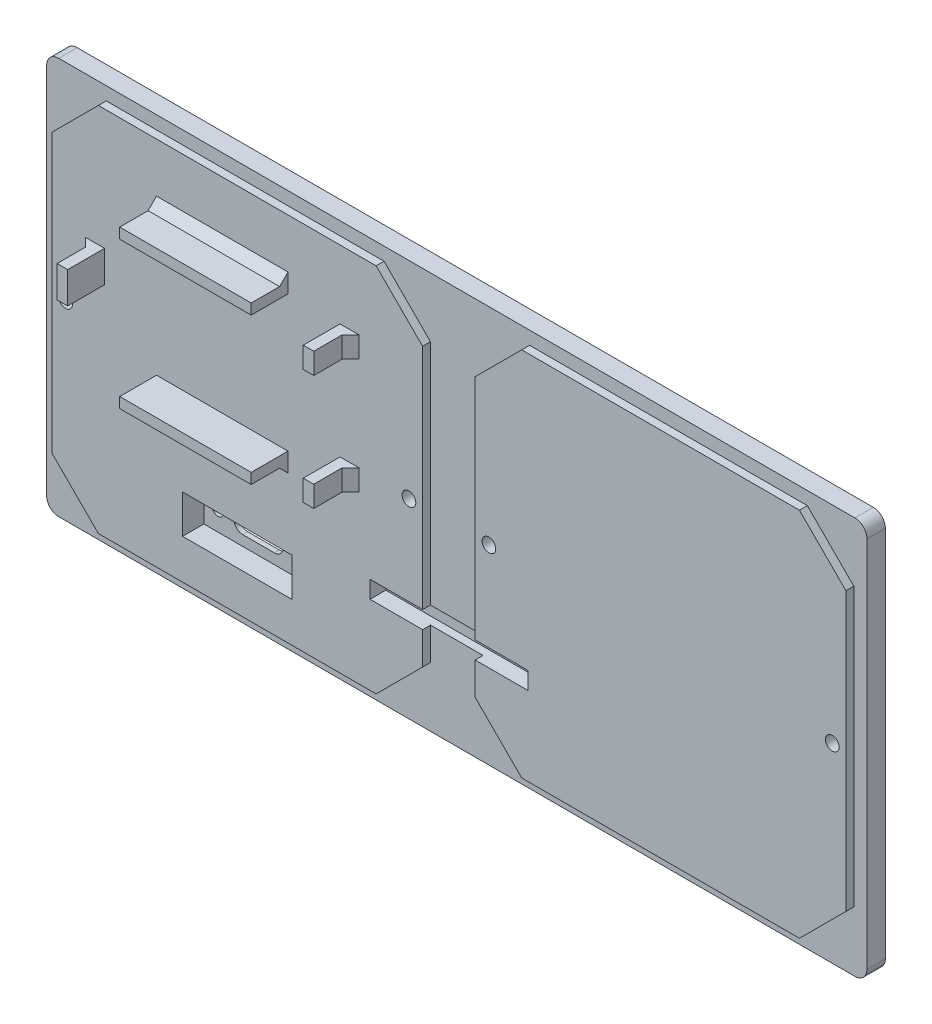
from build123d import *

# Parameters (mm, degrees)
SKETCH_1_W          = 156
SKETCH_1_H          = 75.5
SKETCH_1_R          = 1.3
EXTRUDE_1_DEPTH     = 5
FILLET_1_R          = 2.3
CUT_EXTRUDE_1_DEPTH = 1.5
SKETCH_5_R          = 2.55
SKETCH_5_R_2        = 1.3
CUT_EXTRUDE_4_DEPTH = 2.8
SKETCH_3_R          = 1.05
CUT_EXTRUDE_2_DEPTH = 6
SKETCH_4_W          = 20.8
SKETCH_4_H          = 7.3
CUT_EXTRUDE_3_DEPTH = 4.05
SKETCH_6_W          = 30
SKETCH_6_H          = 3.3
CUT_EXTRUDE_5_DEPTH = 3
SKETCH_7_W          = 25
SKETCH_7_H          = 2
SKETCH_7_W_2        = 2
SKETCH_7_H_2        = 6
SKETCH_7_H_3        = 4
EXTRUDE_2_DEPTH     = 7
CHAMFER_1_SIZE      = 1.6
SKETCH_8_W          = 2.463786805
SKETCH_8_H          = 8
CUT_EXTRUDE_6_DEPTH = 0.5


with BuildPart() as part:
    # 草图1 → 凸台-拉伸1 (new body)
    with BuildSketch(Plane.XY):
        Rectangle(SKETCH_1_W, SKETCH_1_H)
        with Locations((-72.9, 0)):
            Circle(SKETCH_1_R, mode=Mode.SUBTRACT)
        with Locations((-7.6, 0)):
            Circle(SKETCH_1_R, mode=Mode.SUBTRACT)
        with Locations((7.6, 0)):
            Circle(SKETCH_1_R, mode=Mode.SUBTRACT)
        with Locations((72.9, 0)):
            Circle(SKETCH_1_R, mode=Mode.SUBTRACT)
    extrude(amount=EXTRUDE_1_DEPTH)

    # 圆角1
    fillet_1_edges = [part.edges().sort_by_distance(p)[0] for p in [
        (78, -37.75, 2.5),
        (-78, -37.75, 2.5),
        (-78, 37.75, 2.5),
        (78, 37.75, 2.5),
    ]]
    fillet(fillet_1_edges, radius=FILLET_1_R)

    # 草图2 → 切除-拉伸1 (cut)
    with BuildSketch(Plane.XY.offset(5)):
        with BuildLine():
            Line((-75.7, -37.75), (75.7, -37.75))
            ThreePointArc((75.7, -37.75), (77.326345597, -37.076345597), (78, -35.45))
            Line((78, -35.45), (78, 35.45))
            ThreePointArc((78, 35.45), (77.326345597, 37.076345597), (75.7, 37.75))
            Line((75.7, 37.75), (-75.7, 37.75))
            ThreePointArc((-75.7, 37.75), (-77.326345597, 37.076345597), (-78, 35.45))
            Line((-78, 35.45), (-78, -35.45))
            ThreePointArc((-78, -35.45), (-77.326345597, -37.076345597), (-75.7, -37.75))
        make_face()
        Polygon((-75.5, 26.411165235), (-75.5, -26.411165235), (-66.661165235, -35.25), (-13.838834765, -35.25), (-5, -26.411165235), (-5, 26.411165235), (-13.838834765, 35.25), (-66.661165235, 35.25), align=None, mode=Mode.SUBTRACT)
        Polygon((66.661165235, 35.25), (75.5, 26.411165235), (75.5, -26.411165235), (66.661165235, -35.25), (13.838834765, -35.25), (5, -26.411165235), (5, 26.411165235), (13.838834765, 35.25), align=None, mode=Mode.SUBTRACT)
    extrude(amount=-CUT_EXTRUDE_1_DEPTH, mode=Mode.SUBTRACT)

    # 草图5 → 切除-拉伸4 (cut)
    with BuildSketch(Plane(origin=(0, 0, 0), x_dir=(-1, 0, 0), z_dir=(0, 0, -1))):
        with Locations((72.9, 0)):
            Circle(SKETCH_5_R)
        with Locations((72.9, 0)):
            Circle(SKETCH_5_R_2, mode=Mode.SUBTRACT)
        with Locations((7.6, 0)):
            Circle(SKETCH_5_R)
        with Locations((7.6, 0)):
            Circle(SKETCH_5_R_2, mode=Mode.SUBTRACT)
        with Locations((-7.6, 0)):
            Circle(SKETCH_5_R)
        with Locations((-7.6, 0)):
            Circle(SKETCH_5_R_2, mode=Mode.SUBTRACT)
        with Locations((-72.9, 0)):
            Circle(SKETCH_5_R)
        with Locations((-72.9, 0)):
            Circle(SKETCH_5_R_2, mode=Mode.SUBTRACT)
    extrude(amount=-CUT_EXTRUDE_4_DEPTH, mode=Mode.SUBTRACT)

    # 草图3 → 切除-拉伸2 (cut, through all)
    with BuildSketch(Plane(origin=(0, 0, 0), x_dir=(-1, 0, 0), z_dir=(0, 0, -1))):
        with Locations((47.95, -24.05)):
            Circle(SKETCH_3_R)
        with Locations((32.55, -24.05)):
            Circle(SKETCH_3_R)
        with BuildLine():
            Line((37.25, -22.35), (43.25, -22.35))
            ThreePointArc((43.25, -22.35), (44.95, -24.05), (43.25, -25.75))
            Line((43.25, -25.75), (37.25, -25.75))
            ThreePointArc((37.25, -25.75), (35.55, -24.05), (37.25, -22.35))
        make_face()
    extrude(amount=-CUT_EXTRUDE_2_DEPTH, mode=Mode.SUBTRACT)

    # 草图4 → 切除-拉伸3 (cut)
    with BuildSketch(Plane.XY.offset(5)):
        with Locations((-40.25, -24.05)):
            Rectangle(SKETCH_4_W, SKETCH_4_H)
    extrude(amount=-CUT_EXTRUDE_3_DEPTH, mode=Mode.SUBTRACT)

    # 草图6 → 切除-拉伸5 (cut)
    with BuildSketch(Plane.XY.offset(5)):
        with Locations((0, -18.6)):
            Rectangle(SKETCH_6_W, SKETCH_6_H)
    extrude(amount=-CUT_EXTRUDE_5_DEPTH, mode=Mode.SUBTRACT)

    # 草图7 → 凸台-拉伸2 (add)
    with BuildSketch(Plane.XY.offset(5)):
        with Locations((-43.1, 23.25)):
            Rectangle(SKETCH_7_W, SKETCH_7_H)
        with Locations((-66.5, 9.3)):
            Rectangle(SKETCH_7_W_2, SKETCH_7_H_2)
        with Locations((-19.7, 20.25)):
            Rectangle(SKETCH_7_W_2, SKETCH_7_H_3)
        with Locations((-19.7, -1.65)):
            Rectangle(SKETCH_7_W_2, SKETCH_7_H_3)
        with Locations((-43.1, -4.65)):
            Rectangle(SKETCH_7_W, SKETCH_7_H)
    extrude(amount=EXTRUDE_2_DEPTH)

    # 倒角1
    chamfer_1_edges = [part.edges().sort_by_distance(p)[0] for p in [
        (-18.7, -1.65, 5),
        (-18.7, 20.25, 5),
        (-43.1, 24.25, 5),
        (-67.5, 9.3, 5),
        (-43.1, -5.65, 5),
    ]]
    chamfer(chamfer_1_edges, length=CHAMFER_1_SIZE)

    # 草图8 → 切除-拉伸6 (cut)
    with BuildSketch(Plane(origin=(0, 0, 0), x_dir=(-1, 0, 0), z_dir=(0, 0, -1))):
        with BuildLine():
            Line((-26.414210856, 18.390338405), (-26.414210856, 20.652964668))
            add(Edge.make_bspline(
                [(-26.414210856, 20.652964668), (-26.359678019, 20.65405805), (-26.257047942, 20.656115782), (-26.114127978, 20.676912332), (-25.991758174, 20.707870079), (-25.890997156, 20.754581783), (-25.810585553, 20.815106678), (-25.753828372, 20.89152807), (-25.719066321, 20.981436143), (-25.716030587, 21.045791122), (-25.714447263, 21.079356243)],
                knots=[0, 0, 0, 0, 0.00016348, 0.000307668, 0.000432375, 0.000540815, 0.000638831, 0.000730987, 0.000822951, 0.000923204, 0.000923204, 0.000923204, 0.000923204], degree=3))
            add(Edge.make_bspline(
                [(-25.714447263, 21.079356243), (-25.715817062, 21.109230751), (-25.718403571, 21.165640995), (-25.736289996, 21.245528584), (-25.771865042, 21.312076708), (-25.819401012, 21.36771954), (-25.881481297, 21.409296442), (-25.956551854, 21.438472858), (-26.044171961, 21.457716866), (-26.107486225, 21.458770908), (-26.140838838, 21.459326155)],
                knots=[0, 0, 0, 0, 8.9669e-05, 0.000169316, 0.000243147, 0.000313828, 0.000386792, 0.000464695, 0.000554397, 0.000654251, 0.000654251, 0.000654251, 0.000654251], degree=3))
            add(Edge.make_bspline(
                [(-26.140838838, 21.459326155), (-26.165765415, 21.457896018), (-26.213681094, 21.455146904), (-26.280311418, 21.427379433), (-26.337699668, 21.382994583), (-26.381705722, 21.318772687), (-26.416834978, 21.238992898), (-26.438801072, 21.142171263), (-26.455071284, 21.028892846), (-26.456452425, 20.947617442), (-26.457193878, 20.903985515)],
                knots=[0, 0, 0, 0, 7.4429e-05, 0.000143073, 0.000212891, 0.000289241, 0.000373908, 0.000473153, 0.000585975, 0.000716745, 0.000716745, 0.000716745, 0.000716745], degree=3))
            Line((-26.457193878, 20.903985515), (-26.457193878, 15.708197851))
            Line((-26.457193878, 15.708197851), (-29.108386656, 15.708197851))
            Line((-29.108386656, 15.708197851), (-29.108386656, 20.65812263))
            add(Edge.make_bspline(
                [(-29.108386656, 20.65812263), (-29.107362968, 20.74295817), (-29.105355323, 20.909336543), (-29.090656501, 21.152789654), (-29.06183282, 21.384295781), (-29.0274188, 21.604594435), (-28.978715342, 21.812850091), (-28.920582328, 22.0093702), (-28.851901836, 22.193921309), (-28.772086547, 22.367491754), (-28.681180517, 22.532064123), (-28.574461301, 22.686980754), (-28.45856355, 22.837329949), (-28.327133397, 22.977984795), (-28.183469635, 23.111260696), (-28.026481473, 23.236919197), (-27.856034306, 23.355111906), (-27.674822824, 23.466189922), (-27.485592644, 23.567948484), (-27.288710518, 23.653039972), (-27.089015198, 23.727156116), (-26.886259235, 23.790020997), (-26.679133684, 23.836099132), (-26.468281992, 23.868316225), (-26.253620483, 23.890079648), (-26.108798056, 23.892611248), (-26.035960265, 23.893884504)],
                knots=[0, 0, 0, 0, 0.000254512, 0.000499145, 0.000731171, 0.000954186, 0.001167721, 0.001372255, 0.001568657, 0.001757907, 0.001944942, 0.002131875, 0.002321725, 0.002513951, 0.002708607, 0.002909186, 0.003116662, 0.003330446, 0.003546575, 0.003760601, 0.003973304, 0.004185416, 0.004396892, 0.004609178, 0.004825081, 0.005043543, 0.005043543, 0.005043543, 0.005043543], degree=3))
            add(Edge.make_bspline(
                [(-26.035960265, 23.893884504), (-25.929801347, 23.891264376), (-25.72188437, 23.886132737), (-25.416942069, 23.845141815), (-25.125242381, 23.780819757), (-24.846823776, 23.687550294), (-24.582694486, 23.566396664), (-24.33219747, 23.419449272), (-24.094957579, 23.246648337), (-23.875891921, 23.048120508), (-23.675200679, 22.832777937), (-23.498925703, 22.604010013), (-23.351046061, 22.363716069), (-23.2264363, 22.114277373), (-23.132694053, 21.852573022), (-23.065146674, 21.580757004), (-23.024853091, 21.298344525), (-23.01953575, 21.106422536), (-23.01683282, 21.008864088)],
                knots=[0, 0, 0, 0, 0.000318372, 0.000623545, 0.000921365, 0.001213331, 0.001502611, 0.00179159, 0.002083212, 0.002381488, 0.002677116, 0.002965291, 0.003246319, 0.00352236, 0.003800279, 0.004078416, 0.004361442, 0.00465405, 0.00465405, 0.00465405, 0.00465405], degree=3))
            add(Edge.make_bspline(
                [(-23.01683282, 21.008864088), (-23.018985353, 20.911883277), (-23.023191503, 20.722378189), (-23.060637932, 20.446243019), (-23.118370819, 20.184577808), (-23.20084919, 19.937654889), (-23.308409534, 19.705481562), (-23.439271653, 19.487663135), (-23.595327691, 19.286055659), (-23.772399587, 19.099372275), (-23.972884787, 18.932612396), (-24.193757319, 18.784734521), (-24.437767168, 18.663590088), (-24.701648825, 18.563537105), (-24.985187674, 18.484193681), (-25.290476133, 18.430859609), (-25.615580652, 18.394815429), (-25.839852752, 18.391858551), (-25.955152184, 18.390338405)],
                knots=[0, 0, 0, 0, 0.000290814, 0.000568265, 0.000834382, 0.001093726, 0.001347581, 0.001600573, 0.001854363, 0.002110957, 0.002370939, 0.002635116, 0.00290654, 0.003186256, 0.003480762, 0.003788324, 0.00411509, 0.004460827, 0.004460827, 0.004460827, 0.004460827], degree=3))
            Line((-25.955152184, 18.390338405), (-26.414210856, 18.390338405))
        make_face()
        with BuildLine():
            Line((-22.06604838, 21.608907071), (-19.602261576, 21.608907071))
            Line((-19.602261576, 21.608907071), (-19.602261576, 18.268266624))
            add(Edge.make_bspline(
                [(-19.602261576, 18.268266624), (-19.601336768, 18.23960011), (-19.599595428, 18.185623276), (-19.593853423, 18.110126855), (-19.581035831, 18.045436769), (-19.559392997, 17.993549049), (-19.536571657, 17.950086284), (-19.504477888, 17.919803189), (-19.46654282, 17.90091012), (-19.43914049, 17.899388379), (-19.425171526, 17.898612637)],
                knots=[0, 0, 0, 0, 8.6035e-05, 0.000161997, 0.000227082, 0.000282635, 0.000330406, 0.000372974, 0.000412965, 0.000454549, 0.000454549, 0.000454549, 0.000454549], degree=3))
            add(Edge.make_bspline(
                [(-19.425171526, 17.898612637), (-19.401567356, 17.899337369), (-19.357062846, 17.900703817), (-19.294889871, 17.917870135), (-19.242807411, 17.948771155), (-19.199431543, 17.990245039), (-19.165670162, 18.043879808), (-19.144222429, 18.109340332), (-19.130623245, 18.185178464), (-19.128729503, 18.239544437), (-19.127729016, 18.268266624)],
                knots=[0, 0, 0, 0, 7.0681e-05, 0.000133265, 0.000191061, 0.000250644, 0.000311699, 0.000379126, 0.000456016, 0.000542137, 0.000542137, 0.000542137, 0.000542137], degree=3))
            Line((-19.127729016, 18.268266624), (-19.127729016, 21.608907071))
            Line((-19.127729016, 21.608907071), (-16.674258137, 21.608907071))
            Line((-16.674258137, 21.608907071), (-16.674258137, 18.302653041))
            add(Edge.make_bspline(
                [(-16.674258137, 18.302653041), (-16.676485806, 18.209119407), (-16.680862726, 18.025344658), (-16.717932908, 17.75527486), (-16.778584157, 17.496543972), (-16.860134261, 17.247386167), (-16.969908211, 17.010510311), (-17.103288404, 16.784911299), (-17.257973719, 16.568041077), (-17.43856867, 16.367859054), (-17.634032349, 16.181310948), (-17.848997829, 16.021218032), (-18.077028437, 15.884532359), (-18.318785219, 15.771926856), (-18.57558365, 15.685796797), (-18.846322609, 15.624632704), (-19.131163948, 15.585318403), (-19.325891968, 15.581298355), (-19.425171526, 15.579248786)],
                knots=[0, 0, 0, 0, 0.000280508, 0.000551141, 0.000815967, 0.001076941, 0.0013362, 0.001597457, 0.001862283, 0.002133854, 0.002405098, 0.002671593, 0.002936084, 0.003201467, 0.003470055, 0.003746994, 0.004033193, 0.004330878, 0.004330878, 0.004330878, 0.004330878], degree=3))
            add(Edge.make_bspline(
                [(-19.425171526, 15.579248786), (-19.523296337, 15.581403626), (-19.714512281, 15.585602765), (-19.993647218, 15.622888089), (-20.257717383, 15.6820829), (-20.506575243, 15.767702069), (-20.742281483, 15.872767499), (-20.959605108, 16.007911365), (-21.164737248, 16.16252749), (-21.351072871, 16.343647065), (-21.520281815, 16.544651955), (-21.666858889, 16.766362574), (-21.791674998, 17.006364234), (-21.890181261, 17.266079521), (-21.970002258, 17.542490182), (-22.026500837, 17.837646822), (-22.058649627, 18.151783028), (-22.063538207, 18.367340147), (-22.06604838, 18.478023769)],
                knots=[0, 0, 0, 0, 0.00029425, 0.000573406, 0.000843257, 0.00110478, 0.00136176, 0.001615643, 0.001870799, 0.002131014, 0.002393417, 0.002657594, 0.002926738, 0.003203244, 0.003489479, 0.003788908, 0.004103524, 0.004435572, 0.004435572, 0.004435572, 0.004435572], degree=3))
            Line((-22.06604838, 18.478023769), (-22.06604838, 21.608907071))
        make_face()
        with Locations((-14.34199938, 19.708197851)):
            Rectangle(SKETCH_8_W, SKETCH_8_H)
        with BuildLine():
            Line((-8.155023235, 21.608907071), (-8.155023235, 19.148558908))
            add(Edge.make_bspline(
                [(-8.155023235, 19.148558908), (-8.201462588, 19.148518565), (-8.28924187, 19.14844231), (-8.413553875, 19.140229546), (-8.523305979, 19.133138313), (-8.618290583, 19.119902843), (-8.69808485, 19.100779656), (-8.763689894, 19.079428854), (-8.815100749, 19.053814696), (-8.867588214, 19.012680466), (-8.909938601, 18.93170451), (-8.949879812, 18.81305507), (-8.979265637, 18.65776345), (-8.991027225, 18.54287608), (-8.99749046, 18.47974309)],
                knots=[0, 0, 0, 0, 0.000139276, 0.000263258, 0.000373629, 0.000469187, 0.000550506, 0.000619557, 0.000675693, 0.000722146, 0.000817099, 0.000942703, 0.001098821, 0.001289263, 0.001289263, 0.001289263, 0.001289263], degree=3))
            add(Edge.make_bspline(
                [(-8.99749046, 18.47974309), (-9.009406817, 18.367719745), (-9.032647059, 18.149242765), (-9.097278167, 17.834351229), (-9.180664302, 17.54070715), (-9.286118844, 17.269091456), (-9.410945639, 17.018040256), (-9.560176372, 16.789753784), (-9.729052527, 16.582901386), (-9.917754101, 16.395785657), (-10.130946887, 16.235131035), (-10.362822307, 16.093162395), (-10.615081196, 15.971513862), (-10.89030327, 15.876685332), (-11.185321454, 15.801049273), (-11.500873321, 15.746420918), (-11.837667627, 15.713280467), (-12.069265058, 15.709925722), (-12.188549992, 15.708197851)],
                knots=[0, 0, 0, 0, 0.000337797, 0.0006588, 0.000962983, 0.001252575, 0.001531689, 0.001802557, 0.002068935, 0.002331547, 0.002597708, 0.002867812, 0.003146193, 0.003436025, 0.003739605, 0.004059015, 0.00439587, 0.004753638, 0.004753638, 0.004753638, 0.004753638], degree=3))
            Line((-12.188549992, 15.708197851), (-12.590871075, 15.708197851))
            Line((-12.590871075, 15.708197851), (-12.590871075, 18.178861938))
            add(Edge.make_bspline(
                [(-12.590871075, 18.178861938), (-12.536983694, 18.179557394), (-12.434867315, 18.180875281), (-12.289187558, 18.189697285), (-12.15814473, 18.20250722), (-12.042083865, 18.222832767), (-11.941337354, 18.248336826), (-11.855482147, 18.27885482), (-11.784464087, 18.316136695), (-11.707407136, 18.375860503), (-11.63232774, 18.478769087), (-11.568665648, 18.633787661), (-11.525317573, 18.825623833), (-11.512762908, 18.96607505), (-11.505979607, 19.041961014)],
                knots=[0, 0, 0, 0, 0.000161653, 0.000306331, 0.000437722, 0.000556442, 0.000659443, 0.000749195, 0.000829194, 0.000899012, 0.001040007, 0.001204811, 0.001399147, 0.001627558, 0.001627558, 0.001627558, 0.001627558], degree=3))
            add(Edge.make_bspline(
                [(-11.505979607, 19.041961014), (-11.501428214, 19.107869993), (-11.492679834, 19.234555746), (-11.479592294, 19.416342498), (-11.463866744, 19.582546818), (-11.447223854, 19.733382891), (-11.427737576, 19.869075712), (-11.409872967, 19.989165471), (-11.388946925, 20.09352515), (-11.359533349, 20.214384316), (-11.307027444, 20.358953724), (-11.213833634, 20.526992832), (-11.093129366, 20.699003238), (-10.945851614, 20.871179809), (-10.77503179, 21.036459811), (-10.582303609, 21.183080267), (-10.373537445, 21.311128645), (-10.145898557, 21.418366254), (-9.898007599, 21.50541048), (-9.627505061, 21.56626482), (-9.334325426, 21.60261307), (-9.131706954, 21.606758889), (-9.026718915, 21.608907071)],
                knots=[0, 0, 0, 0, 0.0001982, 0.000380966, 0.000546745, 0.000699019, 0.000836155, 0.000957985, 0.001063187, 0.001155343, 0.001331025, 0.001522581, 0.001730057, 0.001960555, 0.002201321, 0.002441695, 0.002685553, 0.002934736, 0.003195195, 0.003472134, 0.003764934, 0.004079799, 0.004079799, 0.004079799, 0.004079799], degree=3))
            Line((-9.026718915, 21.608907071), (-8.155023235, 21.608907071))
        make_face()
        with BuildLine():
            Line((-1.745395038, 18.216686997), (-5.264844855, 18.216686997))
            add(Edge.make_bspline(
                [(-5.264844855, 18.216686997), (-5.282491734, 18.26797805), (-5.31661685, 18.367163474), (-5.349487495, 18.516091439), (-5.37448159, 18.656573113), (-5.377072482, 18.748429404), (-5.378320033, 18.792659488)],
                knots=[0, 0, 0, 0, 0.000162574, 0.000314381, 0.000457126, 0.000589692, 0.000589692, 0.000589692, 0.000589692], degree=3))
            add(Edge.make_bspline(
                [(-5.378320033, 18.792659488), (-5.376513378, 18.840899122), (-5.372747787, 18.941444433), (-5.345027579, 19.098084536), (-5.299980061, 19.265567654), (-5.259891333, 19.379768004), (-5.239055042, 19.439124135)],
                knots=[0, 0, 0, 0, 0.000144679, 0.000301552, 0.000475874, 0.000664538, 0.000664538, 0.000664538, 0.000664538], degree=3))
            Line((-5.239055042, 19.439124135), (-4.188549992, 19.439124135))
            add(Edge.make_bspline(
                [(-4.188549992, 19.439124135), (-4.197271024, 19.472123021), (-4.214123772, 19.535890919), (-4.255423445, 19.623527555), (-4.312002023, 19.697483871), (-4.381789471, 19.758895052), (-4.46587647, 19.80525724), (-4.562430108, 19.838163188), (-4.671572487, 19.856350516), (-4.748409132, 19.858981698), (-4.788592975, 19.860357748)],
                knots=[0, 0, 0, 0, 0.000102267, 0.000197624, 0.000288406, 0.000379789, 0.000474477, 0.000574523, 0.000684479, 0.000805028, 0.000805028, 0.000805028, 0.000805028], degree=3))
            add(Edge.make_bspline(
                [(-4.788592975, 19.860357748), (-4.829254204, 19.856956501), (-4.913413447, 19.849916716), (-5.034889465, 19.791702615), (-5.149549731, 19.698492795), (-5.258593519, 19.573326798), (-5.354390258, 19.414747421), (-5.419214849, 19.221840203), (-5.461414069, 19.000232773), (-5.465536509, 18.842172279), (-5.467724718, 18.758273071)],
                knots=[0, 0, 0, 0, 0.000121574, 0.00025163, 0.000396094, 0.00056301, 0.000747299, 0.000947959, 0.001170177, 0.001421575, 0.001421575, 0.001421575, 0.001421575], degree=3))
            add(Edge.make_bspline(
                [(-5.467724718, 18.758273071), (-5.465080583, 18.672162591), (-5.460080862, 18.509338662), (-5.423256206, 18.279294444), (-5.3590483, 18.078772708), (-5.267690848, 17.911709479), (-5.162669997, 17.77922015), (-5.050868938, 17.683242234), (-4.934444238, 17.619742062), (-4.852315644, 17.611855223), (-4.812663467, 17.60804741)],
                knots=[0, 0, 0, 0, 0.000258265, 0.000488346, 0.000696582, 0.000886627, 0.001056597, 0.001200569, 0.001327438, 0.001445872, 0.001445872, 0.001445872, 0.001445872], degree=3))
            add(Edge.make_bspline(
                [(-4.812663467, 17.60804741), (-4.763416061, 17.612603523), (-4.656957399, 17.622452523), (-4.496043159, 17.691364626), (-4.321947882, 17.794572852), (-4.208625319, 17.885500971), (-4.147286291, 17.934718375)],
                knots=[0, 0, 0, 0, 0.000147591, 0.00031905, 0.000518676, 0.00075423, 0.00075423, 0.00075423, 0.00075423], degree=3))
            Line((-4.147286291, 17.934718375), (-2.761513671, 16.346065893))
            add(Edge.make_bspline(
                [(-2.761513671, 16.346065893), (-2.840662963, 16.284349645), (-2.996614955, 16.162746892), (-3.246784915, 16.008922999), (-3.500769222, 15.874559887), (-3.763607437, 15.768953808), (-4.031060501, 15.683205848), (-4.305644897, 15.623454943), (-4.586397181, 15.586079687), (-4.775868604, 15.581534007), (-4.871120377, 15.579248786)],
                knots=[0, 0, 0, 0, 0.000300881, 0.000592842, 0.00087968, 0.001161921, 0.001441415, 0.001721332, 0.002003898, 0.002289559, 0.002289559, 0.002289559, 0.002289559], degree=3))
            add(Edge.make_bspline(
                [(-4.871120377, 15.579248786), (-4.977275077, 15.581819958), (-5.185827712, 15.586871309), (-5.492957082, 15.628951499), (-5.786814078, 15.699877981), (-6.069812249, 15.795792993), (-6.338896989, 15.922702274), (-6.596221576, 16.075828443), (-6.839833422, 16.258702016), (-7.069964236, 16.464651586), (-7.280576393, 16.691245083), (-7.463362114, 16.935040878), (-7.619510155, 17.190945248), (-7.747761331, 17.460304007), (-7.845502245, 17.743760971), (-7.915743228, 18.0391619), (-7.960574492, 18.347130527), (-7.965242351, 18.556955733), (-7.96761726, 18.663710423)],
                knots=[0, 0, 0, 0, 0.000318372, 0.000625476, 0.000927813, 0.00122414, 0.001520268, 0.001818668, 0.002120926, 0.002432622, 0.002744089, 0.003047378, 0.003345193, 0.003642053, 0.003940567, 0.004242904, 0.004551947, 0.004872036, 0.004872036, 0.004872036, 0.004872036], degree=3))
            add(Edge.make_bspline(
                [(-7.96761726, 18.663710423), (-7.965304744, 18.769908874), (-7.960759837, 18.978626095), (-7.915066561, 19.284524392), (-7.848224072, 19.578395802), (-7.748536765, 19.858506518), (-7.622981135, 20.126996126), (-7.467086722, 20.381320752), (-7.285341605, 20.624327879), (-7.076824779, 20.850601771), (-6.848137451, 21.057734842), (-6.602931327, 21.23942187), (-6.343678305, 21.393150959), (-6.070983397, 21.519926681), (-5.783293334, 21.615458437), (-5.483769698, 21.686636451), (-5.169750355, 21.728549992), (-4.956065934, 21.733573802), (-4.847049885, 21.736136815)],
                knots=[0, 0, 0, 0, 0.000318372, 0.000625712, 0.000925978, 0.001221246, 0.001515818, 0.001813633, 0.002114514, 0.002424817, 0.002735234, 0.003038873, 0.00333875, 0.003637996, 0.003939206, 0.004246561, 0.004560482, 0.004887442, 0.004887442, 0.004887442, 0.004887442], degree=3))
            add(Edge.make_bspline(
                [(-4.847049885, 21.736136815), (-4.737453161, 21.733594036), (-4.522043742, 21.728596272), (-4.206001826, 21.686237718), (-3.903702467, 21.617694803), (-3.614559629, 21.521553439), (-3.340951524, 21.395084505), (-3.080113192, 21.242647432), (-2.834715066, 21.06158311), (-2.605077915, 20.855972168), (-2.397493906, 20.630813233), (-2.213438342, 20.392668315), (-2.057850528, 20.142083551), (-1.930062303, 19.880156295), (-1.83077679, 19.606470841), (-1.76368202, 19.321273449), (-1.717929547, 19.025664576), (-1.713338972, 18.824358137), (-1.711008621, 18.722167333)],
                knots=[0, 0, 0, 0, 0.000328678, 0.000646008, 0.000954649, 0.001257489, 0.001558296, 0.0018573, 0.002162323, 0.002471591, 0.002780629, 0.00307981, 0.00337323, 0.003663892, 0.003952682, 0.004244587, 0.004541716, 0.004848064, 0.004848064, 0.004848064, 0.004848064], degree=3))
            add(Edge.make_bspline(
                [(-1.711008621, 18.722167333), (-1.712221065, 18.704978172), (-1.715775502, 18.654585912), (-1.719492795, 18.552944872), (-1.73389341, 18.401918652), (-1.741229677, 18.283769401), (-1.745395038, 18.216686997)],
                knots=[0, 0, 0, 0, 5.1694e-05, 0.000151548, 0.00030504, 0.00050667, 0.00050667, 0.00050667, 0.00050667], degree=3))
        make_face()
        with BuildLine():
            Line((2.031952909, 15.708197851), (2.031952909, 21.428378379))
            add(Edge.make_bspline(
                [(2.031952909, 21.428378379), (2.033848106, 21.516732758), (2.037564483, 21.689990912), (2.069212381, 21.943144944), (2.120242139, 22.184657095), (2.194735034, 22.412834453), (2.287731454, 22.630614219), (2.403403371, 22.834574917), (2.538260324, 23.027800558), (2.694394152, 23.204813237), (2.865776036, 23.366955752), (3.051579769, 23.507916371), (3.249742467, 23.627842798), (3.459163777, 23.726475252), (3.681990338, 23.799527867), (3.915174821, 23.855587103), (4.161251406, 23.888467776), (4.329442054, 23.892059081), (4.414931633, 23.893884504)],
                knots=[0, 0, 0, 0, 0.000264976, 0.000519604, 0.000764093, 0.001004416, 0.001238528, 0.001473327, 0.001706579, 0.001944175, 0.002180142, 0.002413286, 0.002642395, 0.002873917, 0.003106076, 0.003344616, 0.00359264, 0.003849026, 0.003849026, 0.003849026, 0.003849026], degree=3))
            add(Edge.make_bspline(
                [(4.414931633, 23.893884504), (4.524034372, 23.890822437), (4.734951445, 23.884902858), (5.038526141, 23.832723445), (5.316035497, 23.746638368), (5.569649989, 23.628117327), (5.794879515, 23.470291784), (5.997350127, 23.281590756), (6.170848319, 23.055320743), (6.261540506, 22.885494964), (6.307903909, 22.798677111)],
                knots=[0, 0, 0, 0, 0.000327123, 0.000632393, 0.000920604, 0.001196693, 0.001468541, 0.001742216, 0.002024206, 0.002319138, 0.002319138, 0.002319138, 0.002319138], degree=3))
            add(Edge.make_bspline(
                [(6.307903909, 22.798677111), (6.347373414, 22.885146329), (6.424916094, 23.055025707), (6.590153767, 23.27829464), (6.785593495, 23.469956331), (7.015116235, 23.624948613), (7.274893776, 23.745620334), (7.561220646, 23.832761413), (7.875172061, 23.885019898), (8.092923463, 23.890853992), (8.206034147, 23.893884504)],
                knots=[0, 0, 0, 0, 0.000284494, 0.000558924, 0.000827628, 0.001102311, 0.001385352, 0.001683925, 0.001997672, 0.002336814, 0.002336814, 0.002336814, 0.002336814], degree=3))
            add(Edge.make_bspline(
                [(8.206034147, 23.893884504), (8.301867792, 23.892371313), (8.487897203, 23.889433951), (8.757026418, 23.853422313), (9.008420995, 23.799521647), (9.242016301, 23.721886081), (9.458218528, 23.622308868), (9.655916077, 23.49948566), (9.834730428, 23.353536623), (9.994347883, 23.185575255), (10.137908576, 23.000124502), (10.259604747, 22.794800819), (10.365801434, 22.574525106), (10.448624048, 22.335157708), (10.516982132, 22.080332312), (10.561087679, 21.807813874), (10.59243128, 21.51908709), (10.594714737, 21.320727464), (10.595890154, 21.218621233)],
                knots=[0, 0, 0, 0, 0.000287312, 0.000557721, 0.000813022, 0.001057685, 0.001294609, 0.001525517, 0.001754031, 0.001985074, 0.002219261, 0.002456035, 0.002699821, 0.0029516, 0.003214746, 0.003490337, 0.003778947, 0.004085107, 0.004085107, 0.004085107, 0.004085107], degree=3))
            Line((10.595890154, 21.218621233), (10.595890154, 15.708197851))
            Line((10.595890154, 15.708197851), (7.944697375, 15.708197851))
            Line((7.944697375, 15.708197851), (7.944697375, 20.879915022))
            add(Edge.make_bspline(
                [(7.944697375, 20.879915022), (7.944878129, 20.927516601), (7.945207359, 21.014219509), (7.93554395, 21.130560078), (7.926320449, 21.220968118), (7.907308844, 21.28686075), (7.882163987, 21.333405514), (7.850417613, 21.367253145), (7.80797774, 21.384433183), (7.778047387, 21.38732628), (7.762449363, 21.388833999)],
                knots=[0, 0, 0, 0, 0.000142714, 0.000259943, 0.000350155, 0.000414875, 0.000464139, 0.000507906, 0.000551026, 0.000597954, 0.000597954, 0.000597954, 0.000597954], degree=3))
            add(Edge.make_bspline(
                [(7.762449363, 21.388833999), (7.75166702, 21.387609744), (7.729277628, 21.385067594), (7.702005434, 21.357789921), (7.680370007, 21.31936108), (7.66421272, 21.266346503), (7.650421326, 21.199668333), (7.641114107, 21.117945461), (7.633773118, 21.021604426), (7.633595122, 20.952718425), (7.633500298, 20.916020761)],
                knots=[0, 0, 0, 0, 3.1703e-05, 6.583e-05, 0.000109766, 0.000164135, 0.000230902, 0.000314071, 0.000410599, 0.000520648, 0.000520648, 0.000520648, 0.000520648], degree=3))
            Line((7.633500298, 20.916020761), (7.633500298, 15.708197851))
            Line((7.633500298, 15.708197851), (4.994342765, 15.708197851))
            Line((4.994342765, 15.708197851), (4.994342765, 20.879915022))
            add(Edge.make_bspline(
                [(4.994342765, 20.879915022), (4.994524659, 20.926366135), (4.994855175, 21.010771867), (4.9851591, 21.124869064), (4.975537541, 21.214503124), (4.957324444, 21.282125704), (4.929970923, 21.329978494), (4.896386591, 21.365910588), (4.850401208, 21.384980976), (4.81740408, 21.387506491), (4.800059507, 21.388833999)],
                knots=[0, 0, 0, 0, 0.000139276, 0.000253076, 0.000343287, 0.000409654, 0.000461262, 0.00050746, 0.00055442, 0.000606456, 0.000606456, 0.000606456, 0.000606456], degree=3))
            add(Edge.make_bspline(
                [(4.800059507, 21.388833999), (4.790519253, 21.386763015), (4.770105903, 21.382331716), (4.743502757, 21.355692883), (4.728066164, 21.31274075), (4.709009194, 21.257112719), (4.699899654, 21.18487425), (4.687849507, 21.097490798), (4.684317045, 20.993974381), (4.6835517, 20.919449869), (4.683145688, 20.879915022)],
                knots=[0, 0, 0, 0, 2.8821e-05, 6.1669e-05, 0.00010706, 0.000164702, 0.00023791, 0.000324492, 0.000429498, 0.000548143, 0.000548143, 0.000548143, 0.000548143], degree=3))
            Line((4.683145688, 20.879915022), (4.683145688, 15.708197851))
            Line((4.683145688, 15.708197851), (2.031952909, 15.708197851))
        make_face()
        with BuildLine():
            Line((17.731071757, 18.216686997), (14.21162194, 18.216686997))
            add(Edge.make_bspline(
                [(14.21162194, 18.216686997), (14.193975062, 18.26797805), (14.159849946, 18.367163474), (14.126979301, 18.516091439), (14.101985206, 18.656573113), (14.099394314, 18.748429404), (14.098146763, 18.792659488)],
                knots=[0, 0, 0, 0, 0.000162574, 0.000314381, 0.000457126, 0.000589692, 0.000589692, 0.000589692, 0.000589692], degree=3))
            add(Edge.make_bspline(
                [(14.098146763, 18.792659488), (14.099953418, 18.840899122), (14.103719009, 18.941444433), (14.131439217, 19.098084536), (14.176486735, 19.265567654), (14.216575462, 19.379768004), (14.237411753, 19.439124135)],
                knots=[0, 0, 0, 0, 0.000144679, 0.000301552, 0.000475874, 0.000664538, 0.000664538, 0.000664538, 0.000664538], degree=3))
            Line((14.237411753, 19.439124135), (15.287916804, 19.439124135))
            add(Edge.make_bspline(
                [(15.287916804, 19.439124135), (15.279195771, 19.472123021), (15.262343024, 19.535890919), (15.22104335, 19.623527555), (15.164464773, 19.697483871), (15.094677324, 19.758895052), (15.010590325, 19.80525724), (14.914036687, 19.838163188), (14.804894308, 19.856350516), (14.728057663, 19.858981698), (14.687873821, 19.860357748)],
                knots=[0, 0, 0, 0, 0.000102267, 0.000197624, 0.000288406, 0.000379789, 0.000474477, 0.000574523, 0.000684479, 0.000805028, 0.000805028, 0.000805028, 0.000805028], degree=3))
            add(Edge.make_bspline(
                [(14.687873821, 19.860357748), (14.647212592, 19.856956501), (14.563053349, 19.849916716), (14.44157733, 19.791702615), (14.326917064, 19.698492795), (14.217873277, 19.573326798), (14.122076538, 19.414747421), (14.057251946, 19.221840203), (14.015052726, 19.000232773), (14.010930287, 18.842172279), (14.008742078, 18.758273071)],
                knots=[0, 0, 0, 0, 0.000121574, 0.00025163, 0.000396094, 0.00056301, 0.000747299, 0.000947959, 0.001170177, 0.001421575, 0.001421575, 0.001421575, 0.001421575], degree=3))
            add(Edge.make_bspline(
                [(14.008742078, 18.758273071), (14.011386212, 18.672162591), (14.016385934, 18.509338662), (14.05321059, 18.279294444), (14.117418496, 18.078772708), (14.208775948, 17.911709479), (14.313796799, 17.77922015), (14.425597858, 17.683242234), (14.542022558, 17.619742062), (14.624151151, 17.611855223), (14.663803328, 17.60804741)],
                knots=[0, 0, 0, 0, 0.000258265, 0.000488346, 0.000696582, 0.000886627, 0.001056597, 0.001200569, 0.001327438, 0.001445872, 0.001445872, 0.001445872, 0.001445872], degree=3))
            add(Edge.make_bspline(
                [(14.663803328, 17.60804741), (14.713050735, 17.612603523), (14.819509397, 17.622452523), (14.980423637, 17.691364626), (15.154518914, 17.794572852), (15.267841477, 17.885500971), (15.329180504, 17.934718375)],
                knots=[0, 0, 0, 0, 0.000147591, 0.00031905, 0.000518676, 0.00075423, 0.00075423, 0.00075423, 0.00075423], degree=3))
            Line((15.329180504, 17.934718375), (16.714953124, 16.346065893))
            add(Edge.make_bspline(
                [(16.714953124, 16.346065893), (16.635803833, 16.284349645), (16.47985184, 16.162746892), (16.22968188, 16.008922999), (15.975697574, 15.874559887), (15.712859359, 15.768953808), (15.445406295, 15.683205848), (15.170821899, 15.623454943), (14.890069614, 15.586079687), (14.700598192, 15.581534007), (14.605346419, 15.579248786)],
                knots=[0, 0, 0, 0, 0.000300881, 0.000592842, 0.00087968, 0.001161921, 0.001441415, 0.001721332, 0.002003898, 0.002289559, 0.002289559, 0.002289559, 0.002289559], degree=3))
            add(Edge.make_bspline(
                [(14.605346419, 15.579248786), (14.499191718, 15.581819958), (14.290639084, 15.586871309), (13.983509713, 15.628951499), (13.689652718, 15.699877981), (13.406654547, 15.795792993), (13.137569807, 15.922702274), (12.88024522, 16.075828443), (12.636633374, 16.258702016), (12.40650256, 16.464651586), (12.195890403, 16.691245083), (12.013104682, 16.935040878), (11.85695664, 17.190945248), (11.728705465, 17.460304007), (11.630964551, 17.743760971), (11.560723567, 18.0391619), (11.515892303, 18.347130527), (11.511224445, 18.556955733), (11.508849535, 18.663710423)],
                knots=[0, 0, 0, 0, 0.000318372, 0.000625476, 0.000927813, 0.00122414, 0.001520268, 0.001818668, 0.002120926, 0.002432622, 0.002744089, 0.003047378, 0.003345193, 0.003642053, 0.003940567, 0.004242904, 0.004551947, 0.004872036, 0.004872036, 0.004872036, 0.004872036], degree=3))
            add(Edge.make_bspline(
                [(11.508849535, 18.663710423), (11.511162052, 18.769908874), (11.515706959, 18.978626095), (11.561400235, 19.284524392), (11.628242724, 19.578395802), (11.727930031, 19.858506518), (11.853485661, 20.126996126), (12.009380073, 20.381320752), (12.191125191, 20.624327879), (12.399642017, 20.850601771), (12.628329345, 21.057734842), (12.873535469, 21.23942187), (13.132788491, 21.393150959), (13.405483398, 21.519926681), (13.693173461, 21.615458437), (13.992697097, 21.686636451), (14.306716441, 21.728549992), (14.520400862, 21.733573802), (14.629416911, 21.736136815)],
                knots=[0, 0, 0, 0, 0.000318372, 0.000625712, 0.000925978, 0.001221246, 0.001515818, 0.001813633, 0.002114514, 0.002424817, 0.002735234, 0.003038873, 0.00333875, 0.003637996, 0.003939206, 0.004246561, 0.004560482, 0.004887442, 0.004887442, 0.004887442, 0.004887442], degree=3))
            add(Edge.make_bspline(
                [(14.629416911, 21.736136815), (14.739013634, 21.733594036), (14.954423054, 21.728596272), (15.270464969, 21.686237718), (15.572764329, 21.617694803), (15.861907167, 21.521553439), (16.135515271, 21.395084505), (16.396353603, 21.242647432), (16.641751729, 21.06158311), (16.871388881, 20.855972168), (17.07897289, 20.630813233), (17.263028454, 20.392668315), (17.418616267, 20.142083551), (17.546404493, 19.880156295), (17.645690005, 19.606470841), (17.712784776, 19.321273449), (17.758537248, 19.025664576), (17.763127824, 18.824358137), (17.765458175, 18.722167333)],
                knots=[0, 0, 0, 0, 0.000328678, 0.000646008, 0.000954649, 0.001257489, 0.001558296, 0.0018573, 0.002162323, 0.002471591, 0.002780629, 0.00307981, 0.00337323, 0.003663892, 0.003952682, 0.004244587, 0.004541716, 0.004848064, 0.004848064, 0.004848064, 0.004848064], degree=3))
            add(Edge.make_bspline(
                [(17.765458175, 18.722167333), (17.764245731, 18.704978172), (17.760691293, 18.654585912), (17.756974, 18.552944872), (17.742573385, 18.401918652), (17.735237119, 18.283769401), (17.731071757, 18.216686997)],
                knots=[0, 0, 0, 0, 5.1694e-05, 0.000151548, 0.00030504, 0.00050667, 0.00050667, 0.00050667, 0.00050667], degree=3))
        make_face()
        with BuildLine():
            Line((20.767392411, 23.708197851), (20.767392411, 21.479958005))
            Line((20.767392411, 21.479958005), (21.725054134, 21.479958005))
            Line((21.725054134, 21.479958005), (21.725054134, 19.009293918))
            Line((21.725054134, 19.009293918), (20.767392411, 19.009293918))
            add(Edge.make_bspline(
                [(20.767392411, 19.009293918), (20.769061192, 18.923251578), (20.772122845, 18.76539284), (20.8009414, 18.549135367), (20.852376155, 18.377162333), (20.914417906, 18.260068201), (20.984443419, 18.192129802), (21.051594876, 18.15207151), (21.131579388, 18.114443753), (21.228547937, 18.089346789), (21.339801449, 18.066632485), (21.466104417, 18.049341285), (21.608050202, 18.041959026), (21.707282927, 18.040410741), (21.759440552, 18.039596948)],
                knots=[0, 0, 0, 0, 0.000258104, 0.000473535, 0.000651897, 0.000795211, 0.000864519, 0.000941792, 0.001028733, 0.001128868, 0.001241151, 0.001369538, 0.001510784, 0.00166728, 0.00166728, 0.00166728, 0.00166728], degree=3))
            Line((21.759440552, 18.039596948), (21.759440552, 15.579248786))
            add(Edge.make_bspline(
                [(21.759440552, 15.579248786), (21.618947176, 15.58194733), (21.346545129, 15.587179526), (20.951841583, 15.625717044), (20.585103929, 15.6949893), (20.245378859, 15.788918122), (19.931232476, 15.908288541), (19.646370047, 16.059123349), (19.387310466, 16.234852009), (19.157888133, 16.439299393), (18.955485892, 16.667420319), (18.78119029, 16.919029228), (18.631746715, 17.192318015), (18.513090541, 17.489088048), (18.416995148, 17.806353645), (18.351237738, 18.146236743), (18.311383931, 18.508589847), (18.306245256, 18.757593762), (18.303605607, 18.885502815)],
                knots=[0, 0, 0, 0, 0.000421458, 0.000817163, 0.001188091, 0.00153975, 0.001873409, 0.002194116, 0.002504571, 0.002810267, 0.003113536, 0.003417356, 0.003726642, 0.004045918, 0.004374457, 0.004719736, 0.005082953, 0.005466608, 0.005466608, 0.005466608, 0.005466608], degree=3))
            Line((18.303605607, 18.885502815), (18.303605607, 23.708197851))
            Line((18.303605607, 23.708197851), (20.767392411, 23.708197851))
        make_face()
        with BuildLine():
            Line((28.514652243, 18.216686997), (24.995202426, 18.216686997))
            add(Edge.make_bspline(
                [(24.995202426, 18.216686997), (24.977555547, 18.26797805), (24.943430431, 18.367163474), (24.910559786, 18.516091439), (24.885565692, 18.656573113), (24.882974799, 18.748429404), (24.881727249, 18.792659488)],
                knots=[0, 0, 0, 0, 0.000162574, 0.000314381, 0.000457126, 0.000589692, 0.000589692, 0.000589692, 0.000589692], degree=3))
            add(Edge.make_bspline(
                [(24.881727249, 18.792659488), (24.883533904, 18.840899122), (24.887299494, 18.941444433), (24.915019702, 19.098084536), (24.960067221, 19.265567654), (25.000155948, 19.379768004), (25.020992239, 19.439124135)],
                knots=[0, 0, 0, 0, 0.000144679, 0.000301552, 0.000475874, 0.000664538, 0.000664538, 0.000664538, 0.000664538], degree=3))
            Line((25.020992239, 19.439124135), (26.071497289, 19.439124135))
            add(Edge.make_bspline(
                [(26.071497289, 19.439124135), (26.062776257, 19.472123021), (26.045923509, 19.535890919), (26.004623836, 19.623527555), (25.948045259, 19.697483871), (25.87825781, 19.758895052), (25.794170811, 19.80525724), (25.697617173, 19.838163188), (25.588474794, 19.856350516), (25.511638149, 19.858981698), (25.471454306, 19.860357748)],
                knots=[0, 0, 0, 0, 0.000102267, 0.000197624, 0.000288406, 0.000379789, 0.000474477, 0.000574523, 0.000684479, 0.000805028, 0.000805028, 0.000805028, 0.000805028], degree=3))
            add(Edge.make_bspline(
                [(25.471454306, 19.860357748), (25.430793077, 19.856956501), (25.346633835, 19.849916716), (25.225157816, 19.791702615), (25.11049755, 19.698492795), (25.001453762, 19.573326798), (24.905657023, 19.414747421), (24.840832432, 19.221840203), (24.798633212, 19.000232773), (24.794510772, 18.842172279), (24.792322563, 18.758273071)],
                knots=[0, 0, 0, 0, 0.000121574, 0.00025163, 0.000396094, 0.00056301, 0.000747299, 0.000947959, 0.001170177, 0.001421575, 0.001421575, 0.001421575, 0.001421575], degree=3))
            add(Edge.make_bspline(
                [(24.792322563, 18.758273071), (24.794966698, 18.672162591), (24.799966419, 18.509338662), (24.836791076, 18.279294444), (24.900998982, 18.078772708), (24.992356433, 17.911709479), (25.097377284, 17.77922015), (25.209178343, 17.683242234), (25.325603044, 17.619742062), (25.407731637, 17.611855223), (25.447383814, 17.60804741)],
                knots=[0, 0, 0, 0, 0.000258265, 0.000488346, 0.000696582, 0.000886627, 0.001056597, 0.001200569, 0.001327438, 0.001445872, 0.001445872, 0.001445872, 0.001445872], degree=3))
            add(Edge.make_bspline(
                [(25.447383814, 17.60804741), (25.496631221, 17.612603523), (25.603089883, 17.622452523), (25.764004122, 17.691364626), (25.9380994, 17.794572852), (26.051421962, 17.885500971), (26.11276099, 17.934718375)],
                knots=[0, 0, 0, 0, 0.000147591, 0.00031905, 0.000518676, 0.00075423, 0.00075423, 0.00075423, 0.00075423], degree=3))
            Line((26.11276099, 17.934718375), (27.49853361, 16.346065893))
            add(Edge.make_bspline(
                [(27.49853361, 16.346065893), (27.419384318, 16.284349645), (27.263432326, 16.162746892), (27.013262366, 16.008922999), (26.759278059, 15.874559887), (26.496439845, 15.768953808), (26.228986781, 15.683205848), (25.954402385, 15.623454943), (25.6736501, 15.586079687), (25.484178678, 15.581534007), (25.388926905, 15.579248786)],
                knots=[0, 0, 0, 0, 0.000300881, 0.000592842, 0.00087968, 0.001161921, 0.001441415, 0.001721332, 0.002003898, 0.002289559, 0.002289559, 0.002289559, 0.002289559], degree=3))
            add(Edge.make_bspline(
                [(25.388926905, 15.579248786), (25.282772204, 15.581819958), (25.07421957, 15.586871309), (24.767090199, 15.628951499), (24.473233203, 15.699877981), (24.190235032, 15.795792993), (23.921150293, 15.922702274), (23.663825706, 16.075828443), (23.42021386, 16.258702016), (23.190083045, 16.464651586), (22.979470888, 16.691245083), (22.796685167, 16.935040878), (22.640537126, 17.190945248), (22.51228595, 17.460304007), (22.414545037, 17.743760971), (22.344304053, 18.0391619), (22.299472789, 18.347130527), (22.29480493, 18.556955733), (22.292430021, 18.663710423)],
                knots=[0, 0, 0, 0, 0.000318372, 0.000625476, 0.000927813, 0.00122414, 0.001520268, 0.001818668, 0.002120926, 0.002432622, 0.002744089, 0.003047378, 0.003345193, 0.003642053, 0.003940567, 0.004242904, 0.004551947, 0.004872036, 0.004872036, 0.004872036, 0.004872036], degree=3))
            add(Edge.make_bspline(
                [(22.292430021, 18.663710423), (22.294742538, 18.769908874), (22.299287444, 18.978626095), (22.34498072, 19.284524392), (22.41182321, 19.578395802), (22.511510517, 19.858506518), (22.637066146, 20.126996126), (22.792960559, 20.381320752), (22.974705676, 20.624327879), (23.183222502, 20.850601771), (23.411909831, 21.057734842), (23.657115955, 21.23942187), (23.916368976, 21.393150959), (24.189063884, 21.519926681), (24.476753947, 21.615458437), (24.776277583, 21.686636451), (25.090296926, 21.728549992), (25.303981347, 21.733573802), (25.412997397, 21.736136815)],
                knots=[0, 0, 0, 0, 0.000318372, 0.000625712, 0.000925978, 0.001221246, 0.001515818, 0.001813633, 0.002114514, 0.002424817, 0.002735234, 0.003038873, 0.00333875, 0.003637996, 0.003939206, 0.004246561, 0.004560482, 0.004887442, 0.004887442, 0.004887442, 0.004887442], degree=3))
            add(Edge.make_bspline(
                [(25.412997397, 21.736136815), (25.52259412, 21.733594036), (25.73800354, 21.728596272), (26.054045455, 21.686237718), (26.356344814, 21.617694803), (26.645487652, 21.521553439), (26.919095757, 21.395084505), (27.179934089, 21.242647432), (27.425332215, 21.06158311), (27.654969367, 20.855972168), (27.862553375, 20.630813233), (28.046608939, 20.392668315), (28.202196753, 20.142083551), (28.329984979, 19.880156295), (28.429270491, 19.606470841), (28.496365261, 19.321273449), (28.542117734, 19.025664576), (28.54670831, 18.824358137), (28.549038661, 18.722167333)],
                knots=[0, 0, 0, 0, 0.000328678, 0.000646008, 0.000954649, 0.001257489, 0.001558296, 0.0018573, 0.002162323, 0.002471591, 0.002780629, 0.00307981, 0.00337323, 0.003663892, 0.003952682, 0.004244587, 0.004541716, 0.004848064, 0.004848064, 0.004848064, 0.004848064], degree=3))
            add(Edge.make_bspline(
                [(28.549038661, 18.722167333), (28.547826216, 18.704978172), (28.544271779, 18.654585912), (28.540554486, 18.552944872), (28.526153871, 18.401918652), (28.518817605, 18.283769401), (28.514652243, 18.216686997)],
                knots=[0, 0, 0, 0, 5.1694e-05, 0.000151548, 0.00030504, 0.00050667, 0.00050667, 0.00050667, 0.00050667], degree=3))
        make_face()
        with BuildLine():
            Line((32.764813429, 21.629538921), (32.764813429, 19.160594154))
            add(Edge.make_bspline(
                [(32.764813429, 19.160594154), (32.69037401, 19.180924677), (32.555587502, 19.217736895), (32.373311333, 19.263688027), (32.230391771, 19.292260602), (32.147652704, 19.297624862), (32.11319082, 19.299859144)],
                knots=[0, 0, 0, 0, 0.000231471, 0.000419121, 0.000564136, 0.000667653, 0.000667653, 0.000667653, 0.000667653], degree=3))
            add(Edge.make_bspline(
                [(32.11319082, 19.299859144), (32.09562796, 19.296928795), (32.057336121, 19.290539833), (32.00205638, 19.254026486), (31.950068388, 19.194060499), (31.892098388, 19.115867734), (31.840917384, 19.007856627), (31.810507536, 18.868465757), (31.787047516, 18.700604038), (31.785588809, 18.578431412), (31.784800535, 18.512410187)],
                knots=[0, 0, 0, 0, 5.2965e-05, 0.000115478, 0.000193324, 0.000290659, 0.000406787, 0.000548566, 0.000716831, 0.000914672, 0.000914672, 0.000914672, 0.000914672], degree=3))
            Line((31.784800535, 18.512410187), (31.784800535, 15.708197851))
            Line((31.784800535, 15.708197851), (29.32101373, 15.708197851))
            Line((29.32101373, 15.708197851), (29.32101373, 18.921608553))
            add(Edge.make_bspline(
                [(29.32101373, 18.921608553), (29.322725233, 19.026011204), (29.326072496, 19.230196243), (29.360095045, 19.528434562), (29.412079913, 19.811141076), (29.487631668, 20.077326788), (29.586486841, 20.326252293), (29.704904911, 20.559318607), (29.845306819, 20.776132441), (30.006397706, 20.975248737), (30.186554847, 21.153718209), (30.382636063, 21.309738772), (30.592734811, 21.443730284), (30.8201272, 21.549319326), (31.060199018, 21.635517722), (31.316784712, 21.692107744), (31.587106968, 21.729769161), (31.772630747, 21.733984946), (31.867327936, 21.736136815)],
                knots=[0, 0, 0, 0, 0.000313086, 0.000612317, 0.000899279, 0.00117465, 0.001440923, 0.001701591, 0.001957683, 0.002214387, 0.00246848, 0.002716855, 0.002964896, 0.003214079, 0.003467479, 0.003728567, 0.004000905, 0.004284848, 0.004284848, 0.004284848, 0.004284848], degree=3))
            add(Edge.make_bspline(
                [(31.867327936, 21.736136815), (31.929825899, 21.734460136), (32.063653652, 21.730869841), (32.276171064, 21.711660253), (32.512704143, 21.675706456), (32.677784076, 21.645476179), (32.764813429, 21.629538921)],
                knots=[0, 0, 0, 0, 0.000187532, 0.000401565, 0.000639609, 0.000905037, 0.000905037, 0.000905037, 0.000905037], degree=3))
        make_face()
    extrude(amount=-CUT_EXTRUDE_6_DEPTH, mode=Mode.SUBTRACT)


solid = part.part
